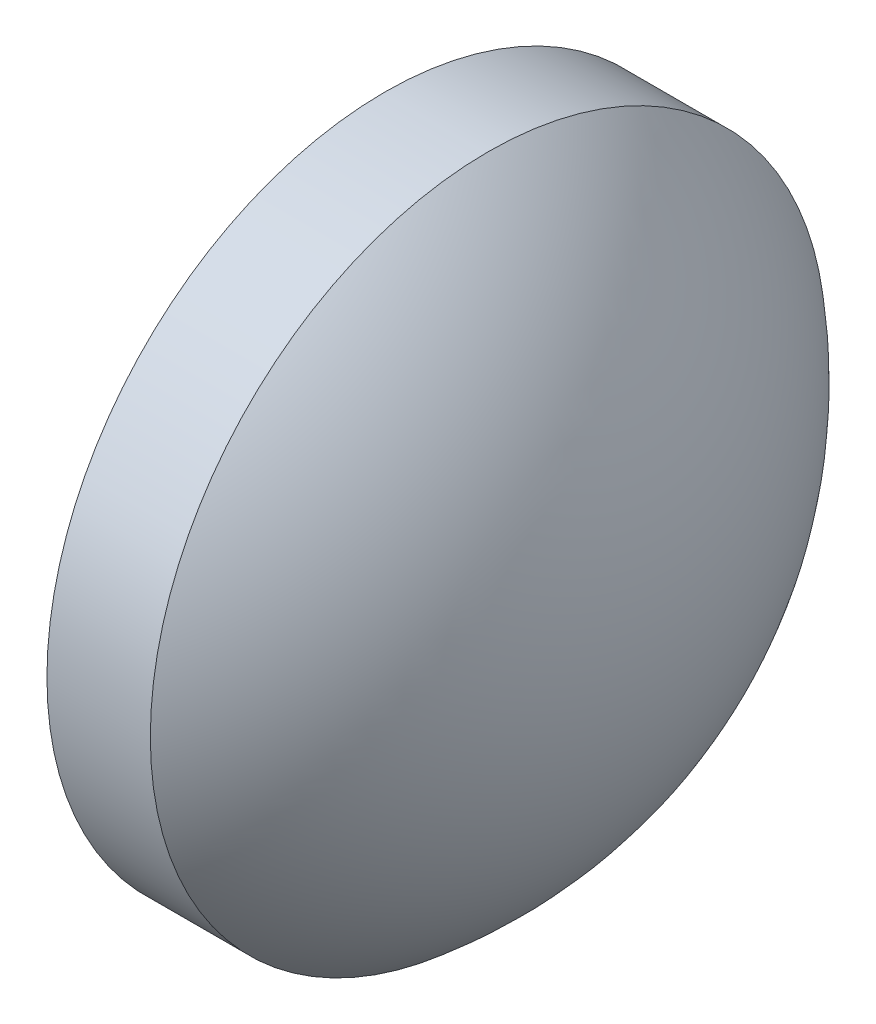
from build123d import *


with BuildPart() as part:
    # 草图1 → 旋转1 (revolve)
    with BuildSketch(Plane.XY):
        with BuildLine():
            Line((535.909627303, 134.376201921), (535.909627303, 139.376201921))
            Line((535.909627303, 139.376201921), (537.439627303, 139.376201921))
            ThreePointArc((537.439627303, 139.376201921), (539.187131539, 137.142828929), (539.809627303, 134.376201921))
            Line((539.809627303, 134.376201921), (535.909627303, 134.376201921))
        make_face()
    revolve(axis=Axis((534.678106729, 134.376201921, 0), (1, 0, 0)))


solid = part.part
